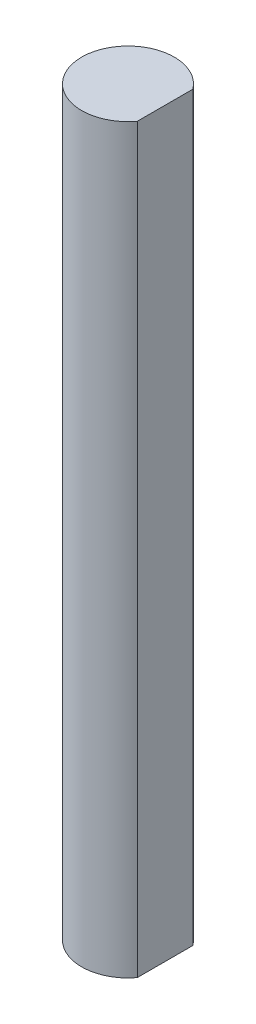
from build123d import *

# Parameters (mm, degrees)
BOSS_EXTRUDE1_DEPTH = 50.8


with BuildPart() as part:
    # Sketch1 → Boss-Extrude1 (new body)
    with BuildSketch(Plane(origin=(0, 0, 0), x_dir=(1, 0, 0), z_dir=(0, 1, 0))):
        with BuildLine():
            Line((2.54, -1.905), (2.54, 1.905))
            ThreePointArc((2.54, 1.905), (-3.175, 0), (2.54, -1.905))
        make_face()
    extrude(amount=BOSS_EXTRUDE1_DEPTH)


solid = part.part
